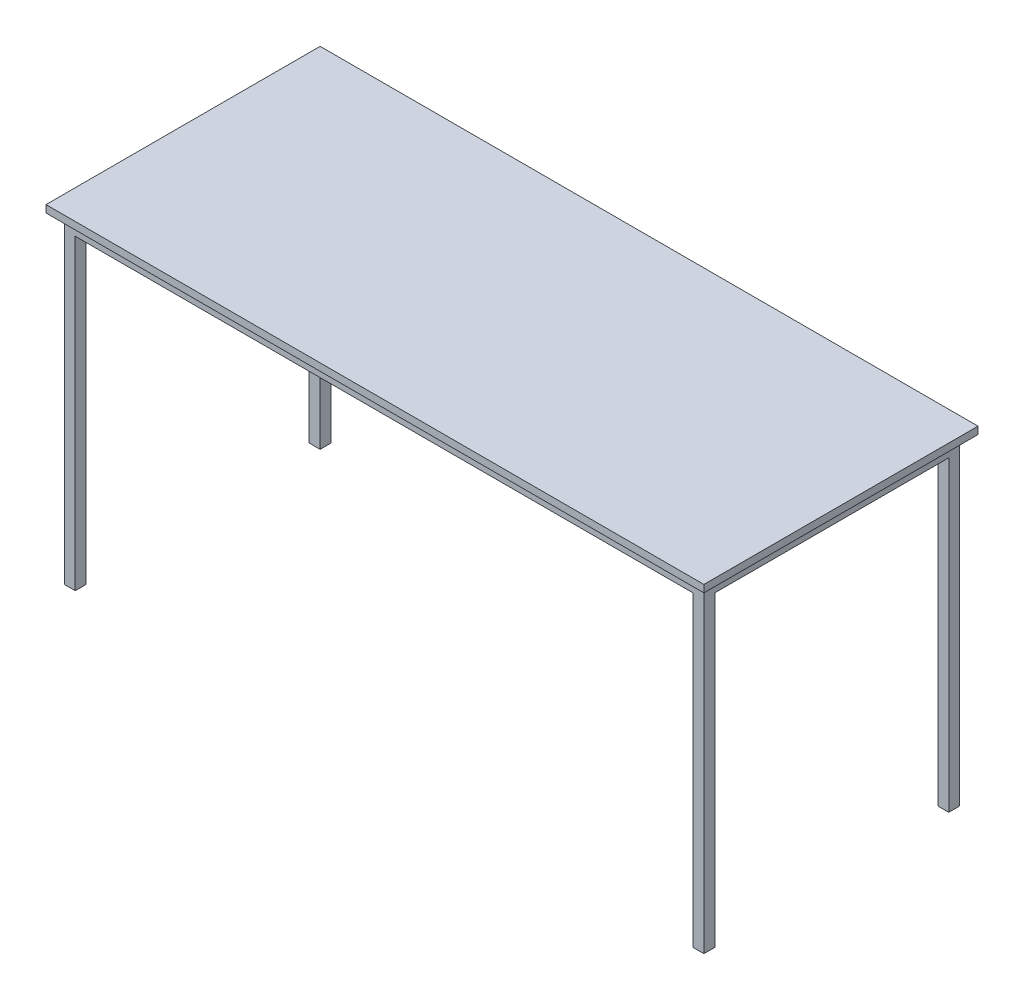
from build123d import *

# Parameters (mm, degrees)
SKETCH1_W           = 1750
SKETCH1_H           = 700
SKETCH1_W_2         = 1690
SKETCH1_H_2         = 640
EXTRUDE_THIN1_DEPTH = 40
SKETCH2_W           = 30
SKETCH2_H           = 30
BOSS_EXTRUDE1_DEPTH = 880
SKETCH3_W           = 1800
SKETCH3_H           = 750
BOSS_EXTRUDE2_DEPTH = 20


with BuildPart() as part:
    # Sketch1 → Extrude-Thin1 (new body)
    with BuildSketch(Plane(origin=(0, 0, 0), x_dir=(1, 0, 0), z_dir=(0, 1, 0))):
        with Locations((875, 350)):
            Rectangle(SKETCH1_W, SKETCH1_H)
        with Locations((875, 350)):
            Rectangle(SKETCH1_W_2, SKETCH1_H_2, mode=Mode.SUBTRACT)
    extrude(amount=-EXTRUDE_THIN1_DEPTH)

    # Sketch2 → Boss-Extrude1 (add)
    with BuildSketch(Plane(origin=(0, 0, 0), x_dir=(1, 0, 0), z_dir=(0, 1, 0))):
        with Locations((15, 685)):
            Rectangle(SKETCH2_W, SKETCH2_H)
        with Locations((15, 15)):
            Rectangle(SKETCH2_W, SKETCH2_H)
        with Locations((1735, 15)):
            Rectangle(SKETCH2_W, SKETCH2_H)
        with Locations((1735, 685)):
            Rectangle(SKETCH2_W, SKETCH2_H)
    extrude(amount=-BOSS_EXTRUDE1_DEPTH)


with BuildPart() as body_2:
    # Sketch3 → Boss-Extrude2 (new body)
    with BuildSketch(Plane(origin=(0, 0, 0), x_dir=(1, 0, 0), z_dir=(0, 1, 0))):
        with Locations((875, 350)):
            Rectangle(SKETCH3_W, SKETCH3_H)
    extrude(amount=BOSS_EXTRUDE2_DEPTH)


solid = Compound([part.part, body_2.part])
